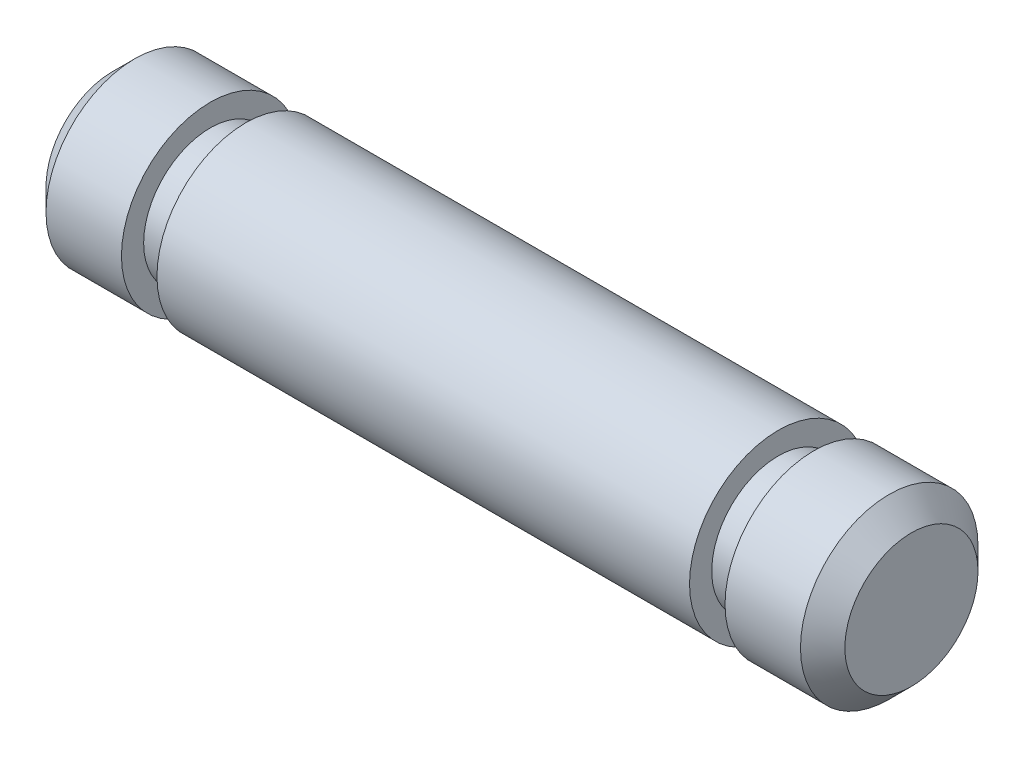
from build123d import *

# Parameters (mm, degrees)
SKETCH1_R           = 2
BOSS_EXTRUDE1_DEPTH = 18
CHAMFER1_SIZE       = 0.5
CUT_EXTRUDE1_START  = -3
SKETCH2_R           = 2
SKETCH2_R_2         = 1.5
CUT_EXTRUDE1_DEPTH  = 0.8
CUT_EXTRUDE2_START  = -3
SKETCH3_R           = 2
SKETCH3_R_2         = 1.5
CUT_EXTRUDE2_DEPTH  = 0.8


with BuildPart() as part:
    # Sketch1 → Boss-Extrude1 (new body)
    with BuildSketch(Plane(origin=(0, 0, 0), x_dir=(0, 0, -1), z_dir=(1, 0, 0))):
        Circle(SKETCH1_R)
    extrude(amount=BOSS_EXTRUDE1_DEPTH)

    # Chamfer1
    chamfer1_edges = [part.edges().sort_by_distance(p)[0] for p in [
        (0, 0, 2),
        (18, 0, 2),
    ]]
    chamfer(chamfer1_edges, length=CHAMFER1_SIZE)

    # Sketch2 → Cut-Extrude1 (cut)
    with BuildSketch(Plane(origin=(18, 0, 0), x_dir=(0, 0, -1), z_dir=(1, 0, 0)).offset(CUT_EXTRUDE1_START)):
        Circle(SKETCH2_R)
        Circle(SKETCH2_R_2, mode=Mode.SUBTRACT)
    extrude(amount=CUT_EXTRUDE1_DEPTH, mode=Mode.SUBTRACT)

    # Sketch3 → Cut-Extrude2 (cut)
    with BuildSketch(Plane.ZY.offset(CUT_EXTRUDE2_START)):
        Circle(SKETCH3_R)
        Circle(SKETCH3_R_2, mode=Mode.SUBTRACT)
    extrude(amount=CUT_EXTRUDE2_DEPTH, mode=Mode.SUBTRACT)


solid = part.part
